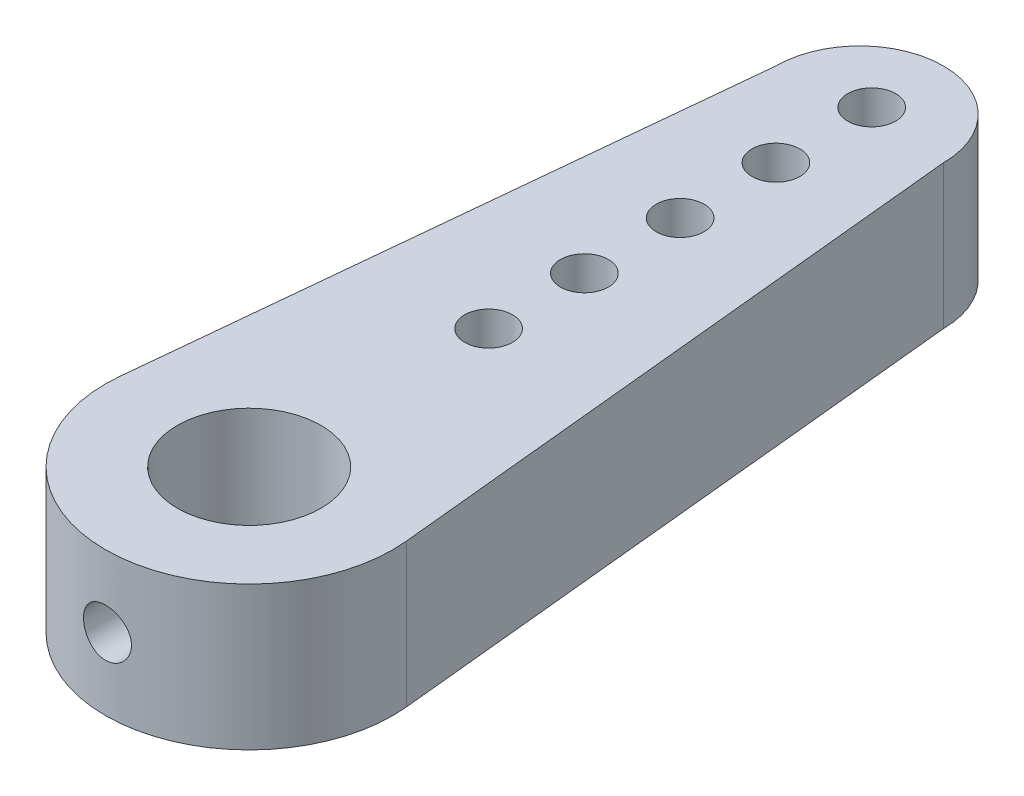
from build123d import *

# Parameters (mm, degrees)
SKETCH1_R           = 1.5
SKETCH1_R_2         = 0.5
BOSS_EXTRUDE1_DEPTH = 3
SKETCH2_R           = 0.5
CUT_EXTRUDE1_DEPTH  = 3


with BuildPart() as part:
    # Sketch1 → Boss-Extrude1 (new body)
    with BuildSketch(Plane(origin=(0, 0, 0), x_dir=(1, 0, 0), z_dir=(0, 1, 0))):
        with BuildLine():
            Line((-1.75, 12.75), (-2.985348867, 0.296128587))
            ThreePointArc((-2.985348867, 0.296128587), (0, -3), (2.985348867, 0.296128587))
            Line((2.985348867, 0.296128587), (1.75, 12.75))
            ThreePointArc((1.75, 12.75), (0, 14.5), (-1.75, 12.75))
        make_face()
        Circle(SKETCH1_R, mode=Mode.SUBTRACT)
        with Locations((0, 5)):
            Circle(SKETCH1_R_2, mode=Mode.SUBTRACT)
        with Locations((0, 7)):
            Circle(SKETCH1_R_2, mode=Mode.SUBTRACT)
        with Locations((0, 9)):
            Circle(SKETCH1_R_2, mode=Mode.SUBTRACT)
        with Locations((0, 11)):
            Circle(SKETCH1_R_2, mode=Mode.SUBTRACT)
        with Locations((0, 13)):
            Circle(SKETCH1_R_2, mode=Mode.SUBTRACT)
    extrude(amount=BOSS_EXTRUDE1_DEPTH)

    # Sketch2 → Cut-Extrude1 (cut)
    with BuildSketch(Plane.XY.offset(3)):
        with Locations((0, 1.5)):
            Circle(SKETCH2_R)
    extrude(amount=-CUT_EXTRUDE1_DEPTH, mode=Mode.SUBTRACT)


solid = part.part
